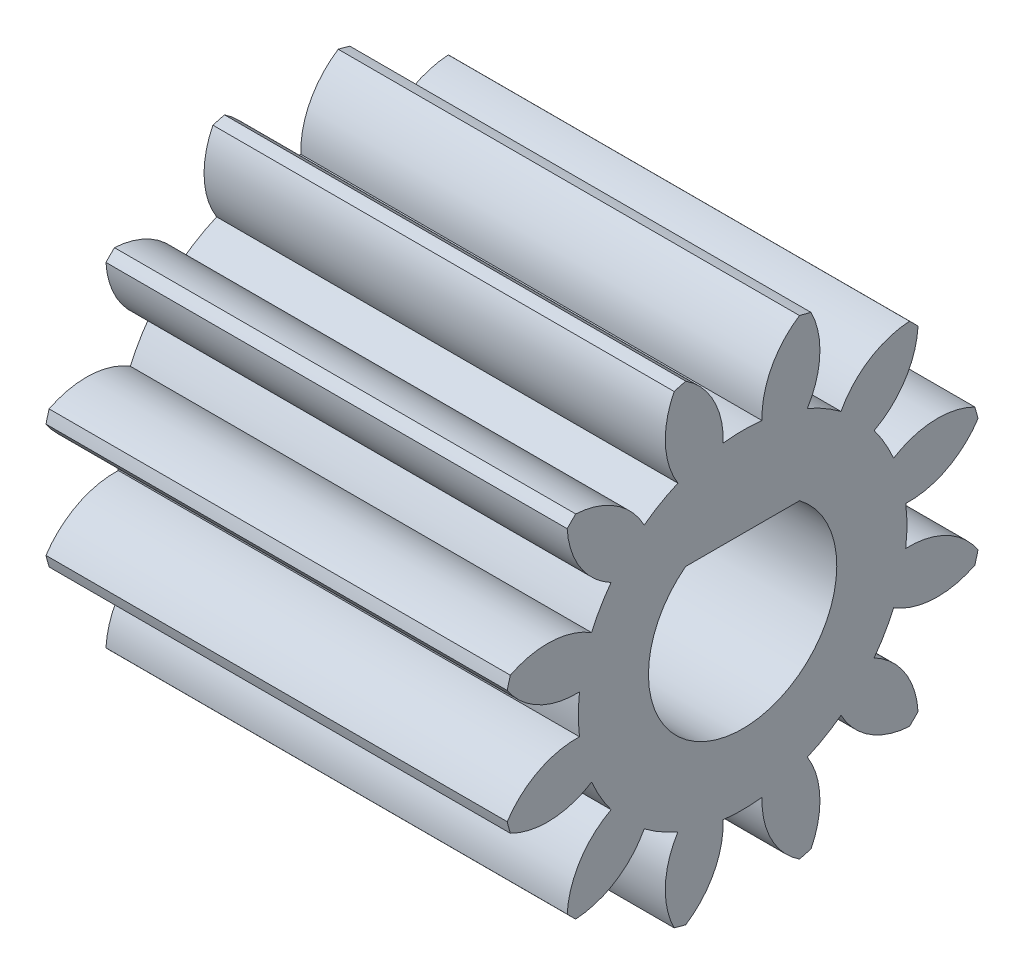
from build123d import *

# Parameters (mm, degrees)
BASPROSKE_W     = 12
BASPROSKE_H     = 6.3
TOOTHCUT_DEPTH  = 15.945902448
TEETHCUTS_COUNT = 12
TEETHCUTS_ANGLE = 330
BORE_DEPTH      = 50.0000508


with BuildPart() as part:
    # BasProSke → Base-Revolve (revolve)
    with BuildSketch(Plane(origin=(0, 0, 0), x_dir=(1, 0, 0), z_dir=(0, 1, 0)), mode=Mode.PRIVATE) as base_revolve_sk:
        with Locations((6, 3.15)):
            Rectangle(BASPROSKE_W, BASPROSKE_H)
    revolve(base_revolve_sk.sketch.rotate(Axis((-10, 0, 0), (1, 0, 0)), 180), axis=Axis((-10, 0, 0), (1, 0, 0)))

    # TooCutSke → ToothCut (cut, through all)
    with BuildSketch(Plane(origin=(0, 0, 0), x_dir=(0, 0, -1), z_dir=(1, 0, 0))):
        with BuildLine():
            ThreePointArc((0.505712998, 4.243975773), (0, 4.274), (-0.505712998, 4.243975773))
            ThreePointArc((-0.505712998, 4.243975773), (-0.754225381, 5.326869831), (-1.508135905, 6.142980649))
            ThreePointArc((-1.508135905, 6.142980649), (0, 6.3254), (1.508135905, 6.142980649))
            ThreePointArc((1.508135905, 6.142980649), (0.754225381, 5.326869831), (0.505712998, 4.243975773))
        make_face()
    toothcut = extrude(amount=TOOTHCUT_DEPTH, mode=Mode.SUBTRACT)

    # TeethCuts: ToothCut ×12 about axis
    teethcuts_axis = Axis((-10, 0, 0), (1, 0, 0))
    for i in range(1, TEETHCUTS_COUNT):
        add(toothcut.rotate(teethcuts_axis, i * TEETHCUTS_ANGLE / (TEETHCUTS_COUNT - 1)), mode=Mode.SUBTRACT)

    # BorSke → Bore (cut, symmetric)
    with BuildSketch(Plane(origin=(0, 0, 0), x_dir=(0, 0, -1), z_dir=(1, 0, 0))):
        with BuildLine():
            Line((-1.483239697, 1.95), (1.483239697, 1.95))
            ThreePointArc((1.483239697, 1.95), (0, -2.45), (-1.483239697, 1.95))
        make_face()
    extrude(amount=BORE_DEPTH, both=True, mode=Mode.SUBTRACT)


solid = part.part
